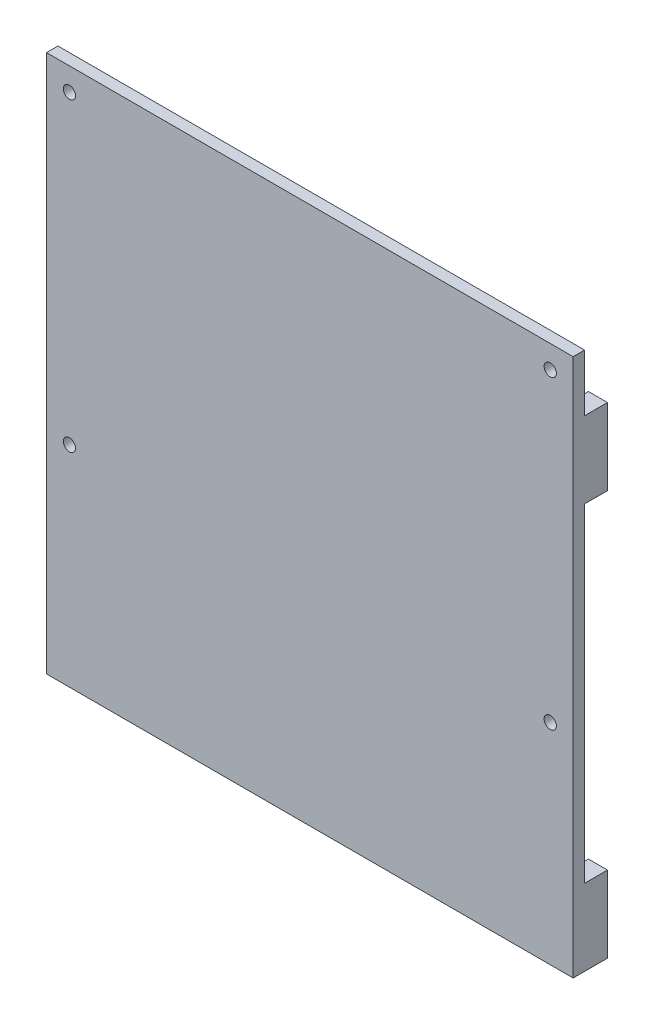
from build123d import *

# Parameters (mm, degrees)
SKETCH_1_W      = 138
SKETCH_1_H      = 141
SKETCH_1_R      = 1.6
EXTRUDE_1_DEPTH = 3
SKETCH_2_W      = 5
SKETCH_2_H      = 20
EXTRUDE_2_DEPTH = 6


with BuildPart() as part:
    # 草图1 → 凸台-拉伸1 (new body)
    with BuildSketch(Plane.XY):
        with Locations((14.838842975, -46.124397743)):
            Rectangle(SKETCH_1_W, SKETCH_1_H)
        with Locations((-48.161157025, 18.375602257)):
            Circle(SKETCH_1_R, mode=Mode.SUBTRACT)
        with Locations((77.838842975, 18.375602257)):
            Circle(SKETCH_1_R, mode=Mode.SUBTRACT)
        with Locations((-48.161157025, -61.624397743)):
            Circle(SKETCH_1_R, mode=Mode.SUBTRACT)
        with Locations((77.838842975, -61.624397743)):
            Circle(SKETCH_1_R, mode=Mode.SUBTRACT)
    extrude(amount=EXTRUDE_1_DEPTH)

    # 草图2 → 凸台-拉伸2 (add)
    with BuildSketch(Plane(origin=(0, 0, 0), x_dir=(-1, 0, 0), z_dir=(0, 0, -1))):
        with Locations((-81.338842975, -106.624397743)):
            Rectangle(SKETCH_2_W, SKETCH_2_H)
        with Locations((-81.338842975, -0.534764205)):
            Rectangle(SKETCH_2_W, SKETCH_2_H)
        with Locations((51.661157025, -106.624397743)):
            Rectangle(SKETCH_2_W, SKETCH_2_H)
        with Locations((51.661157025, -0.534764205)):
            Rectangle(SKETCH_2_W, SKETCH_2_H)
    extrude(amount=EXTRUDE_2_DEPTH)


solid = part.part
